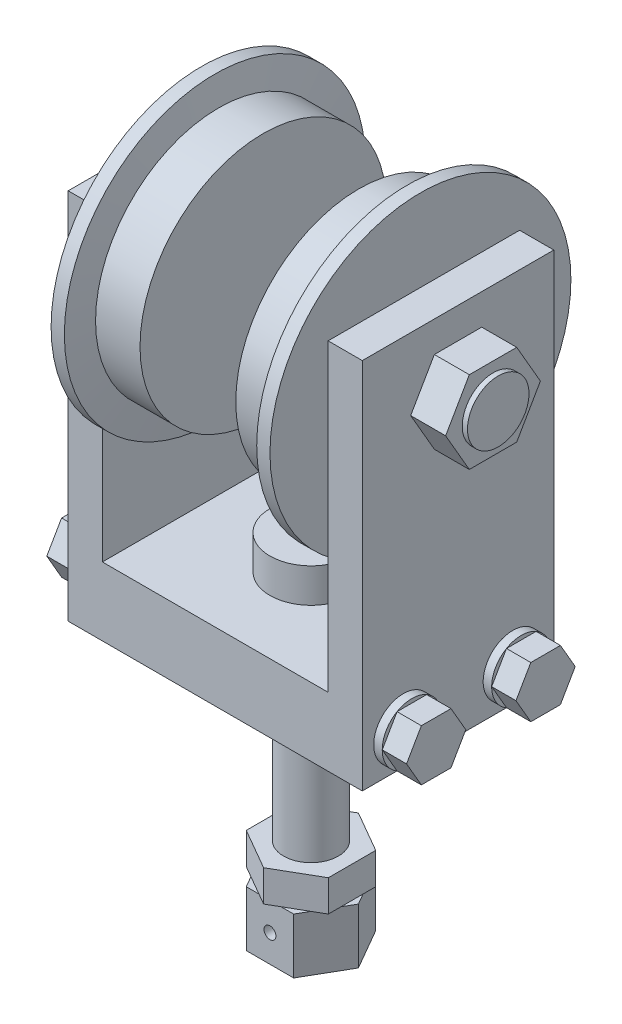
from build123d import *

# Parameters (mm, degrees)
YOKE_CROSS_SECTION_W           = 88.9
YOKE_CROSS_SECTION_H           = 31.75
YOKE_DEPTH                     = 52.3875
SIDEPLATE_PROFILE_W            = 88.9
SIDEPLATE_PROFILE_H            = 173.0375
SIDEPLATE_DEPTH                = 15.875
WHEEL_PIN_NUT_DEPTH            = 16.2306
WHEEL_PIN_PROJECTION_PROFILE_R = 14.2875
WHEEL_PIN_PROJECTION_DEPTH     = 2.413
LOCKNUTS_PROFILE_R             = 13.7541
LOCKNUTS_DEPTH                 = 3.9624
SCREWS_DEPTH                   = 11.2776
PROFILE_R                      = 19.05
KING_BOLT_HEAD_DEPTH           = 15.875
DIA_R                          = 12.7
KING_BOLT_DEPTH                = 76.2
KING_BOLT_JAM_NUT_DEPTH        = 14.605
KING_BOLT_NUT_DEPTH            = 25.7048
SKETCH5_R                      = 12.7
EXTENDED_KING_BOLT_DEPTH       = 6.35
CHAMFER1_SIZE                  = 2.38125
COTTER_PIN_HOLE_REACH          = 90.9
SKETCH8_R                      = 2.7686


with BuildPart() as part:
    # YOKE CROSS SECTION → YOKE (new body)
    with BuildSketch(Plane(origin=(0, 0, 0), x_dir=(0, 0, -1), z_dir=(1, 0, 0))):
        with Locations((0, 15.875)):
            Rectangle(YOKE_CROSS_SECTION_W, YOKE_CROSS_SECTION_H)
    extrude(amount=YOKE_DEPTH)

    # SIDEPLATE PROFILE → SIDEPLATE (add)
    with BuildSketch(Plane(origin=(52.3875, 0, 0), x_dir=(0, 0, -1), z_dir=(1, 0, 0))):
        with Locations((0, 86.51875)):
            Rectangle(SIDEPLATE_PROFILE_W, SIDEPLATE_PROFILE_H)
    extrude(amount=SIDEPLATE_DEPTH)

    # WHEEL PIN NUT PROFILE → WHEEL PIN NUT (add)
    with BuildSketch(Plane(origin=(68.2625, 0, 0), x_dir=(0, 0, -1), z_dir=(1, 0, 0))):
        Polygon((21.997045256, 139.7), (10.998522628, 158.75), (-10.998522628, 158.75), (-21.997045256, 139.7), (-10.998522628, 120.65), (10.998522628, 120.65), align=None)
    extrude(amount=WHEEL_PIN_NUT_DEPTH)

    # WHEEL PIN PROJECTION PROFILE → WHEEL PIN PROJECTION (add)
    with BuildSketch(Plane(origin=(84.4931, 0, 0), x_dir=(0, 0, -1), z_dir=(1, 0, 0))):
        with Locations((0, 139.7)):
            Circle(WHEEL_PIN_PROJECTION_PROFILE_R)
    extrude(amount=WHEEL_PIN_PROJECTION_DEPTH)

    # LOCKNUTS PROFILE → LOCKNUTS (add)
    with BuildSketch(Plane(origin=(68.2625, 0, 0), x_dir=(0, 0, -1), z_dir=(1, 0, 0))):
        with Locations((-25.4, 15.875)):
            Circle(LOCKNUTS_PROFILE_R)
    locknuts = extrude(amount=LOCKNUTS_DEPTH)

    # SCREWS PROFILE → SCREWS (add)
    with BuildSketch(Plane(origin=(72.2249, 0, 0), x_dir=(0, 0, -1), z_dir=(1, 0, 0))):
        Polygon((-11.651846715, 15.875), (-18.525923357, 27.78125), (-32.274076643, 27.78125), (-39.148153285, 15.875), (-32.274076643, 3.96875), (-18.525923357, 3.96875), align=None)
    screws = extrude(amount=SCREWS_DEPTH)

    # PROFILE → KING BOLT HEAD (add)
    with BuildSketch(Plane(origin=(0, 31.75, 0), x_dir=(-1, 0, 0), z_dir=(0, 1, 0))):
        with Locations(Location((0, 0, 0), (0, 0, 90))):  # turned: the seam where the file's is
            Circle(PROFILE_R)
    extrude(amount=KING_BOLT_HEAD_DEPTH)

    # Mirror1: LOCKNUTS, SCREWS across plane
    add(locknuts.mirror(Plane.XY))
    add(screws.mirror(Plane.XY))

    # Mirror5: part across plane


with BuildPart() as part_1:
    add(part.part)
    add(part.part.mirror(Plane(origin=(0, 0, 0), x_dir=(0, 0, 1), z_dir=(1, 0, 0))))

    # DIA. → KING BOLT (add)
    with BuildSketch(Plane.XZ):
        with Locations(Location((0, 0, 0), (0, 0, 90))):  # turned: the seam where the file's is
            Circle(DIA_R)
    extrude(amount=KING_BOLT_DEPTH)

    # KING BOLT JAN NUT PROFILE → KING BOLT JAM NUT (add)
    with BuildSketch(Plane.XZ.offset(76.2)):
        Polygon((0, -21.997045256), (19.05, -10.998522628), (19.05, 10.998522628), (0, 21.997045256), (-19.05, 10.998522628), (-19.05, -10.998522628), align=None)
    extrude(amount=KING_BOLT_JAM_NUT_DEPTH)

    # KING BOLT NUT PROFILE → KING BOLT NUT (add)
    with BuildSketch(Plane.XZ.offset(90.805)):
        Polygon((21.997045256, 0), (10.998522628, 19.05), (-10.998522628, 19.05), (-21.997045256, 0), (-10.998522628, -19.05), (10.998522628, -19.05), align=None)
    extrude(amount=KING_BOLT_NUT_DEPTH)

    # Sketch5 → EXTENDED KING BOLT (add)
    with BuildSketch(Plane.XZ.offset(116.5098)):
        with Locations(Location((0, 0, 0), (0, 0, 90))):  # turned: the seam where the file's is
            Circle(SKETCH5_R)
    extrude(amount=EXTENDED_KING_BOLT_DEPTH)

    # Chamfer1
    chamfer1_edges = [part_1.edges().sort_by_distance(p)[0] for p in [
        (0, -122.8598, -12.7),
    ]]
    chamfer(chamfer1_edges, length=CHAMFER1_SIZE)

    # Sketch7 → WHEEL (revolve)
    with BuildSketch(Plane.XY, mode=Mode.PRIVATE) as wheel_sk:
        Polygon((50.8, 155.575), (50.8, 209.55), (44.647368601, 209.55), (42.8625, 196.85), (22.225, 196.85), (22.225, 139.7), (52.3875, 139.7), (52.3875, 155.575), align=None)
    wheel = revolve(wheel_sk.sketch.rotate(Axis((86.9061, 139.7, 0), (-1, 0, 0)), 90), axis=Axis((86.9061, 139.7, 0), (-1, 0, 0)))  # turned: the seam where the file's is

    # Mirror6: WHEEL across plane
    add(wheel.mirror(Plane(origin=(0, 0, 0), x_dir=(0, 0, 1), z_dir=(1, 0, 0))))

    # Sketch8 → COTTER PIN HOLE (cut, up to next)
    with BuildSketch(Plane.XY.offset(19.05), mode=Mode.PRIVATE) as cotter_pin_hole_sk1:
        with Locations((0, -103.8098)):
            Circle(SKETCH8_R)
    cotter_pin_hole_tool1 = extrude(cotter_pin_hole_sk1.sketch, amount=-COTTER_PIN_HOLE_REACH, mode=Mode.PRIVATE) & part_1.part
    add(cotter_pin_hole_tool1.solids().sort_by_distance((0, -103.8098, 19.05))[0], mode=Mode.SUBTRACT)


solid = part_1.part
